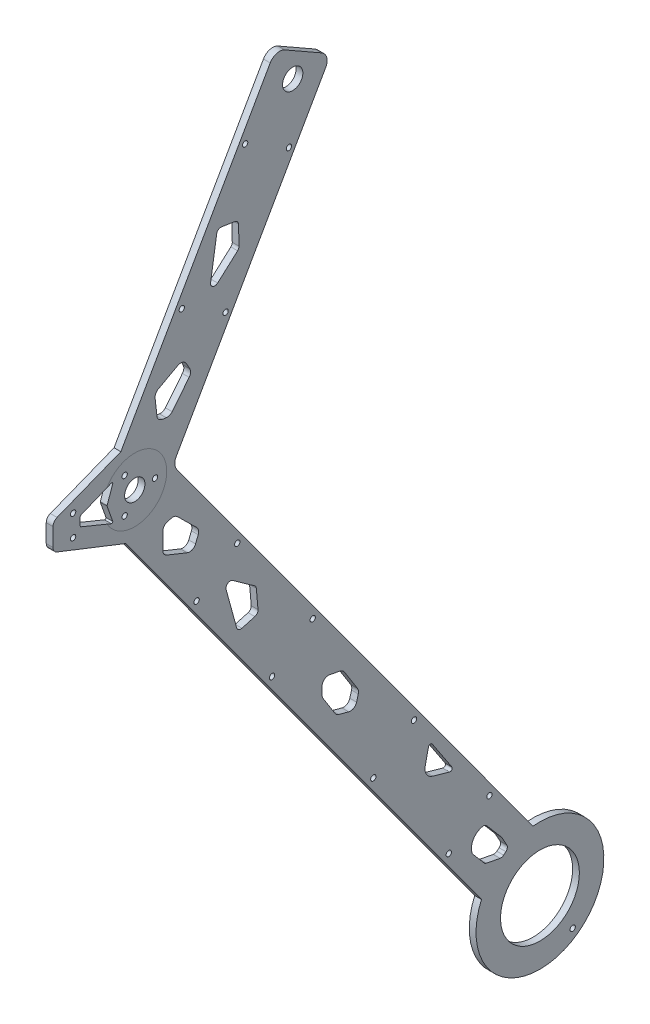
from build123d import *

# Parameters (mm, degrees)
SKETCH3_R                           = 4.765
SKETCH3_R_2                         = 1.25
SKETCH3_R_3                         = 18.5
BOSS_ROCKER_BASE_DEPTH              = 3.18
SKETCH4_R                           = 1.25
CUT_MOTOR_HOLES_SHAFT_SUPPORT_DEPTH = 3.18
SKETCH5_R                           = 1.25
CUT_SUPPORT_HOLES_DEPTH             = 3.18
CUT_LIGHTENING_HOLES_DEPTH          = 3.18


with BuildPart() as part:
    # Sketch3 → Boss-rocker base (new body)
    with BuildSketch(Plane.YZ):
        with BuildLine():
            Line((-19.740098585, 194.326279503), (-247.886058825, 27.445444598))
            ThreePointArc((-247.886058825, 27.445444598), (-284.213703097, -17.711481653), (-230.174577172, 3.231741502))
            Line((-230.174577172, 3.231741502), (-1.602441241, 170.424309102))
            ThreePointArc((-1.602441241, 170.424309102), (1.066332673, 171.380668673), (3.826130086, 170.732211983))
            Line((3.826130086, 170.732211983), (126.91354691, 100.548260636))
            ThreePointArc((126.91354691, 100.548260636), (130.710275653, 100.069186741), (133.733724692, 102.415122982))
            Line((133.733724692, 102.415122982), (143.640355564, 119.789203239))
            ThreePointArc((143.640355564, 119.789203239), (144.119429459, 123.585931982), (141.773493218, 126.609381021))
            Line((141.773493218, 126.609381021), (18.794188293, 196.731687397))
            Line((18.794188293, 196.731687397), (7.025536002, 226.658847865))
            ThreePointArc((7.025536002, 226.658847865), (5.922779586, 228.040238472), (4.233648495, 228.560957093))
            Line((4.233648495, 228.560957093), (-4.233648495, 228.560957093))
            ThreePointArc((-4.233648495, 228.560957093), (-5.922779586, 228.040238472), (-7.025536002, 226.658847865))
            Line((-7.025536002, 226.658847865), (-19.740098585, 194.326279503))
        make_face()
        with Locations((0, 190.180957093)):
            Circle(SKETCH3_R, mode=Mode.SUBTRACT)
        with Locations((130, 116.055478547)):
            Circle(SKETCH3_R, mode=Mode.SUBTRACT)
        with Locations((-5, 219.130957093)):
            Circle(SKETCH3_R_2, mode=Mode.SUBTRACT)
        with Locations((5, 219.130957093)):
            Circle(SKETCH3_R_2, mode=Mode.SUBTRACT)
        with Locations((-260, 0)):
            Circle(SKETCH3_R_3, mode=Mode.SUBTRACT)
    extrude(amount=BOSS_ROCKER_BASE_DEPTH)

    # Sketch4 → Cut-motor holes + shaft support (cut)
    with BuildSketch(Plane.YZ):
        with Locations((0, 180.656752709)):
            Circle(SKETCH4_R)
        with Locations((-8.24, 194.928851363)):
            Circle(SKETCH4_R)
        with Locations((8.24, 194.928851363)):
            Circle(SKETCH4_R)
    extrude(amount=CUT_MOTOR_HOLES_SHAFT_SUPPORT_DEPTH, mode=Mode.SUBTRACT)

    # Sketch5 → Cut-support holes (cut)
    with BuildSketch(Plane.YZ):
        with Locations((-173.097100025, 78.211048963)):
            Circle(SKETCH5_R)
        with Locations((-159.140452483, 59.130650922)):
            Circle(SKETCH5_R)
        with Locations((-94.167013372, 106.656461829)):
            Circle(SKETCH5_R)
        with Locations((-108.123660914, 125.73685987)):
            Circle(SKETCH5_R)
        with Locations((-221.524503751, 42.788087462)):
            Circle(SKETCH5_R)
        with Locations((-207.567856209, 23.707689422)):
            Circle(SKETCH5_R)
        with Locations((-45.739607178, 142.079425135)):
            Circle(SKETCH5_R)
        with Locations((-59.69625472, 161.159823175)):
            Circle(SKETCH5_R)
        with Locations((103.007538851, 117.839995969)):
            Circle(SKETCH5_R)
        with Locations((114.717176541, 138.376158833)):
            Circle(SKETCH5_R)
        with Locations((62.594935771, 168.096051448)):
            Circle(SKETCH5_R)
        with Locations((50.885298081, 147.559888585)):
            Circle(SKETCH5_R)
        with Locations((-280.985209351, -15.349950766)):
            Circle(SKETCH5_R)
    extrude(amount=CUT_SUPPORT_HOLES_DEPTH, mode=Mode.SUBTRACT)

    # Sketch6 → Cut-lightening holes (cut)
    with BuildSketch(Plane.YZ):
        with BuildLine():
            Line((-79.983471427, 142.368791683), (-61.979782767, 147.316428458))
            ThreePointArc((-61.979782767, 147.316428458), (-59.811067724, 146.534457497), (-59.819745898, 144.229088067))
            Line((-59.819745898, 144.229088067), (-67.122963599, 133.95613022))
            ThreePointArc((-67.122963599, 133.95613022), (-67.760393878, 133.378682327), (-68.581402, 133.122344477))
            Line((-68.581402, 133.122344477), (-77.604831251, 132.34516891))
            ThreePointArc((-77.604831251, 132.34516891), (-78.919471752, 132.69660063), (-79.704956379, 133.807815192))
            Line((-79.704956379, 133.807815192), (-81.381998087, 139.910311831))
            ThreePointArc((-81.381998087, 139.910311831), (-81.191902606, 141.429196112), (-79.983471427, 142.368791683))
        make_face()
        with BuildLine():
            Line((-23.474916203, 177.031971532), (-31.234891161, 177.031971532))
            ThreePointArc((-31.234891161, 177.031971532), (-32.91387852, 176.518133523), (-34.017714198, 175.152639164))
            Line((-34.017714198, 175.152639164), (-37.880265406, 165.561216901))
            ThreePointArc((-37.880265406, 165.561216901), (-37.857627092, 163.26522791), (-36.218110002, 161.657726231))
            Line((-36.218110002, 161.657726231), (-33.122502329, 160.411097438))
            ThreePointArc((-33.122502329, 160.411097438), (-31.392547815, 160.256443753), (-29.866816812, 161.086386695))
            Line((-29.866816812, 161.086386695), (-20.893300564, 170.176925526))
            ThreePointArc((-20.893300564, 170.176925526), (-20.132536099, 171.500594144), (-20.121734598, 173.027271748))
            Line((-20.121734598, 173.027271748), (-20.568332353, 174.774783973))
            ThreePointArc((-20.568332353, 174.774783973), (-21.634866927, 176.401405781), (-23.474916203, 177.031971532))
        make_face()
        with BuildLine():
            Line((-123.842513182, 102.258163939), (-127.383477271, 102.258163939))
            ThreePointArc((-127.383477271, 102.258163939), (-128.217930269, 102.139776022), (-128.986523832, 101.793956069))
            Line((-128.986523832, 101.793956069), (-137.87452461, 96.175246667))
            ThreePointArc((-137.87452461, 96.175246667), (-138.681600876, 95.425877769), (-139.163866001, 94.435753436))
            Line((-139.163866001, 94.435753436), (-140.452603638, 89.754685534))
            ThreePointArc((-140.452603638, 89.754685534), (-140.168511172, 87.476227852), (-138.356514585, 86.065998684))
            Line((-138.356514585, 86.065998684), (-135.427175254, 85.259526758))
            ThreePointArc((-135.427175254, 85.259526758), (-134.189854142, 85.184508534), (-133.027829794, 85.61612258))
            Line((-133.027829794, 85.61612258), (-123.19292846, 91.833432183))
            ThreePointArc((-123.19292846, 91.833432183), (-122.319685125, 92.675710701), (-121.851449189, 93.794970338))
            Line((-121.851449189, 93.794970338), (-120.89798735, 98.683909964))
            ThreePointArc((-120.89798735, 98.683909964), (-121.527047578, 101.165680397), (-123.842513182, 102.258163939))
        make_face()
        with BuildLine():
            Line((-173.179518759, 50.529751316), (-187.062617136, 41.348992712))
            ThreePointArc((-187.062617136, 41.348992712), (-188.206182034, 41.377149334), (-188.575130176, 42.459928509))
            Line((-188.575130176, 42.459928509), (-186.300929891, 50.354284082))
            ThreePointArc((-186.300929891, 50.354284082), (-184.055505641, 53.265590831), (-180.426317386, 53.854343461))
            Line((-180.426317386, 53.854343461), (-173.517109299, 52.340698989))
            ThreePointArc((-173.517109299, 52.340698989), (-172.74804587, 51.547125046), (-173.179518759, 50.529751316))
        make_face()
        with BuildLine():
            Line((-227.536912906, 31.443521835), (-233.642526561, 26.214778226))
            ThreePointArc((-233.642526561, 26.214778226), (-234.07149562, 25.699434586), (-234.306028267, 25.071272219))
            Line((-234.306028267, 25.071272219), (-235.520501126, 18.719097413))
            ThreePointArc((-235.520501126, 18.719097413), (-235.489047738, 17.830056904), (-235.075165658, 17.0426028))
            Line((-235.075165658, 17.0426028), (-234.178175321, 15.995185513))
            ThreePointArc((-234.178175321, 15.995185513), (-233.016054277, 15.328216057), (-231.693713026, 15.544519522))
            Line((-231.693713026, 15.544519522), (-227.597149989, 17.802325732))
            ThreePointArc((-227.597149989, 17.802325732), (-227.423433386, 17.909992398), (-227.261611665, 18.034825485))
            Line((-227.261611665, 18.034825485), (-219.133655325, 24.995468947))
            ThreePointArc((-219.133655325, 24.995468947), (-218.552793599, 25.837124808), (-218.463915883, 26.855891554))
            ThreePointArc((-218.463915883, 26.855891554), (-221.531743706, 31.287956059), (-226.896432107, 31.812247659))
            ThreePointArc((-226.896432107, 31.812247659), (-227.233851743, 31.657725269), (-227.536912906, 31.443521835))
        make_face()
        with BuildLine():
            Line((85.568117513, 143.181930885), (86.544369033, 149.434919538))
            ThreePointArc((86.544369033, 149.434919538), (86.183746182, 150.922567652), (84.87682125, 151.719494858))
            Line((84.87682125, 151.719494858), (66.429148509, 154.599648582))
            ThreePointArc((66.429148509, 154.599648582), (64.362763101, 153.577467158), (64.632063287, 151.28786437))
            Line((64.632063287, 151.28786437), (73.050048081, 141.906596667))
            ThreePointArc((73.050048081, 141.906596667), (73.74868466, 141.404929088), (74.593412473, 141.243070035))
            Line((74.593412473, 141.243070035), (83.646848899, 141.491195361))
            ThreePointArc((83.646848899, 141.491195361), (84.913320183, 141.989025039), (85.568117513, 143.181930885))
        make_face()
        with BuildLine():
            Line((21.93232317, 175.41253387), (22.178458249, 177.199337176))
            ThreePointArc((22.178458249, 177.199337176), (23.054223795, 178.936124213), (24.811171332, 179.770707856))
            Line((24.811171332, 179.770707856), (32.521378103, 180.648160365))
            ThreePointArc((32.521378103, 180.648160365), (34.247699157, 180.327467884), (35.498857547, 179.095546323))
            Line((35.498857547, 179.095546323), (40.421178328, 170.0023928))
            ThreePointArc((40.421178328, 170.0023928), (40.658302188, 167.718569205), (39.211066927, 165.935990164))
            Line((39.211066927, 165.935990164), (36.27627425, 164.347323378))
            ThreePointArc((36.27627425, 164.347323378), (34.574902041, 163.998048434), (32.965111147, 164.650147857))
            Line((32.965111147, 164.650147857), (23.021241192, 172.667712351))
            ThreePointArc((23.021241192, 172.667712351), (22.115683157, 173.896868902), (21.93232317, 175.41253387))
        make_face()
        with BuildLine():
            Line((1.921390016, 215.785081873), (-1.921390016, 215.785081873))
            ThreePointArc((-1.921390016, 215.785081873), (-2.199739759, 215.700438853), (-2.38384805, 215.475167556))
            Line((-2.38384805, 215.475167556), (-8.248888496, 201.206154542))
            ThreePointArc((-8.248888496, 201.206154542), (-8.149028051, 200.671797182), (-7.620562901, 200.544382574))
            Line((-7.620562901, 200.544382574), (-0.165867561, 203.165811621))
            ThreePointArc((-0.165867561, 203.165811621), (0, 203.194125335), (0.165867561, 203.165811621))
            Line((0.165867561, 203.165811621), (7.620562901, 200.544382574))
            ThreePointArc((7.620562901, 200.544382574), (8.149028051, 200.671797182), (8.248888496, 201.206154542))
            Line((8.248888496, 201.206154542), (2.38384805, 215.475167556))
            ThreePointArc((2.38384805, 215.475167556), (2.199739759, 215.700438853), (1.921390016, 215.785081873))
        make_face()
    extrude(amount=CUT_LIGHTENING_HOLES_DEPTH, mode=Mode.SUBTRACT)


solid = part.part
